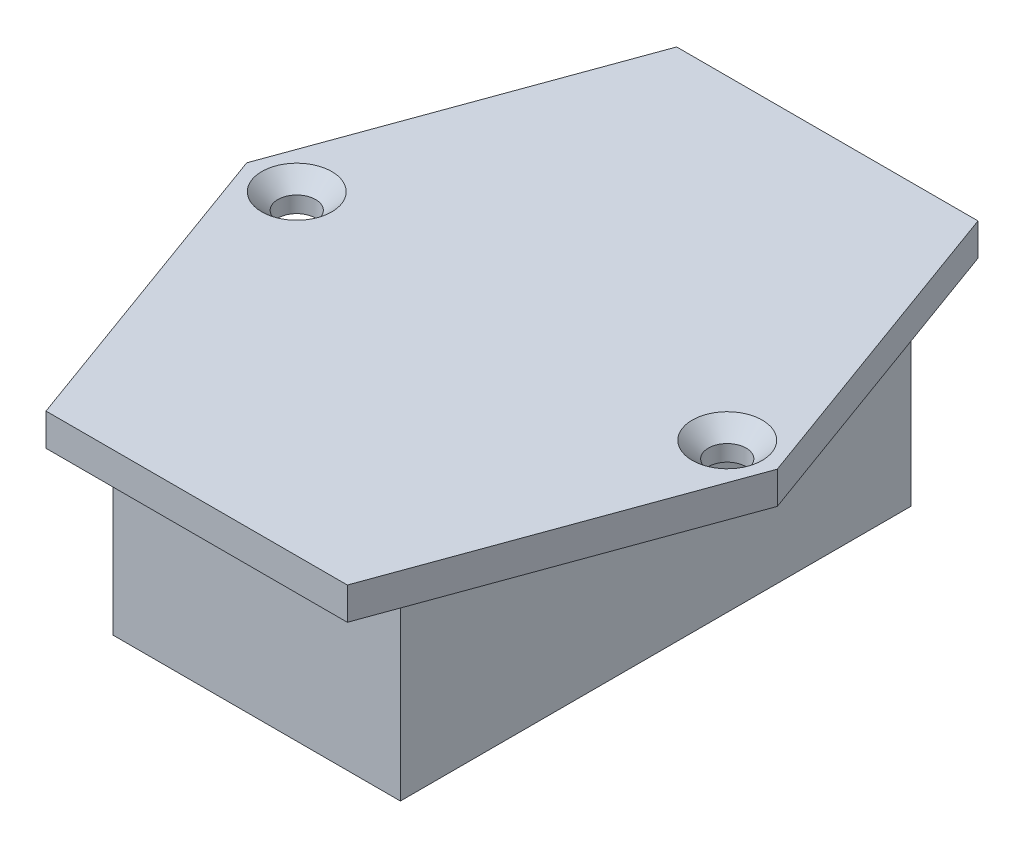
from build123d import *

# Parameters (mm, degrees)
BOSS_EXTRUDE1_DEPTH = 3
SKETCH2_W           = 26.7
SKETCH2_H           = 47.44
BOSS_EXTRUDE2_DEPTH = 17.5
SKETCH3_W           = 5
SKETCH3_H           = 0.75
BOSS_EXTRUDE3_DEPTH = 10
SKETCH4_R           = 1.75
CUT_EXTRUDE1_DEPTH  = 3
CHAMFER1_SIZE       = 1.5


with BuildPart() as part:
    # Sketch1 → Boss-Extrude1 (new body)
    with BuildSketch(Plane(origin=(0, 0, 0), x_dir=(1, 0, 0), z_dir=(0, 1, 0))):
        Polygon((14, 29.3), (-14, 29.3), (-24.65, 0), (-14, -29.3), (14, -29.3), (24.65, 0), align=None)
    extrude(amount=BOSS_EXTRUDE1_DEPTH)

    # Sketch2 → Boss-Extrude2 (add)
    with BuildSketch(Plane.XZ):
        Rectangle(SKETCH2_W, SKETCH2_H)
    extrude(amount=BOSS_EXTRUDE2_DEPTH)

    # Sketch4 → Cut-Extrude1 (cut)
    with BuildSketch(Plane(origin=(0, 3, 0), x_dir=(1, 0, 0), z_dir=(0, 1, 0))):
        with Locations((20, 0)):
            Circle(SKETCH4_R)
        with Locations((-20, 0)):
            Circle(SKETCH4_R)
    extrude(amount=-CUT_EXTRUDE1_DEPTH, mode=Mode.SUBTRACT)

    # Chamfer1
    chamfer1_edges = [part.edges().sort_by_distance(p)[0] for p in [
        (18.25, 3, 0),
        (-21.75, 3, 0),
    ]]
    chamfer(chamfer1_edges, length=CHAMFER1_SIZE)


with BuildPart() as body_2:
    # Sketch3 → Boss-Extrude3 (new body)
    with BuildSketch(Plane.XZ.offset(17.5)):
        with Locations((0, -19.845)):
            Rectangle(SKETCH3_W, SKETCH3_H)
    extrude(amount=BOSS_EXTRUDE3_DEPTH)


solid = Compound([part.part, body_2.part])
